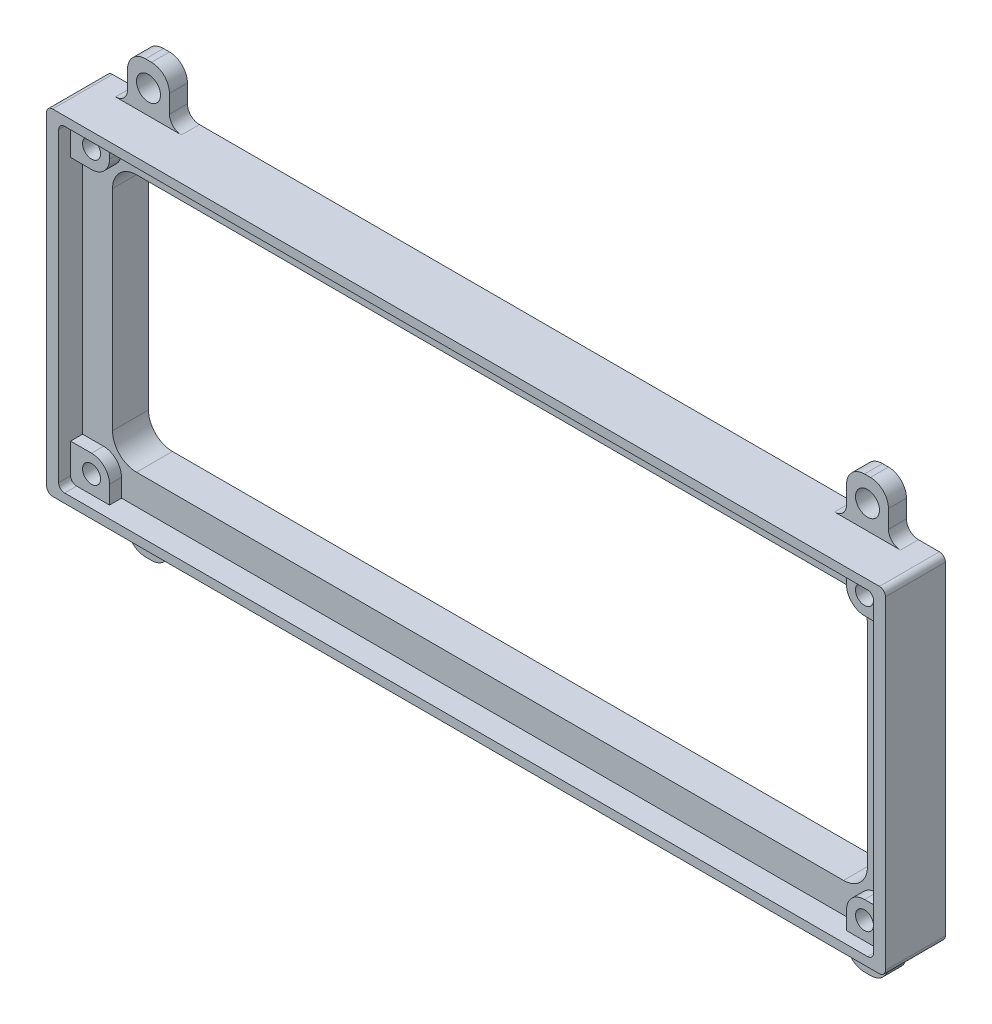
from build123d import *

# Parameters (mm, degrees)
SKETCH1_R               = 1.5
BOSS_EXTRUDE1_DEPTH     = 6
BOSS_EXTRUDE2_START     = 4
BOSS_EXTRUDE2_DEPTH     = 4
CUT_EXTRUDE1_DEPTH      = 151.903942957
CUT_EXTRUDE1_DEPTH_BACK = 151.903942957
SKETCH3_R               = 2
BOSS_EXTRUDE3_DEPTH     = 3
FILLET1_R               = 2
BOSS_EXTRUDE4_START     = 2
SKETCH4_R               = 1.5
BOSS_EXTRUDE4_DEPTH     = 2


with BuildPart() as part:
    # Sketch1 → Boss-Extrude1 (new body)
    with BuildSketch(Plane.XY):
        with BuildLine():
            ThreePointArc((0, 1), (0.292893219, 0.292893219), (1, 0))
            Line((1, 0), (139, 0))
            ThreePointArc((139, 0), (139.707106781, 0.292893219), (140, 1))
            Line((140, 1), (140, 55))
            ThreePointArc((140, 55), (139.707106781, 55.707106781), (139, 56))
            Line((139, 56), (1, 56))
            ThreePointArc((1, 56), (0.292893219, 55.707106781), (0, 55))
            Line((0, 55), (0, 1))
        make_face()
        with Locations((5.5, 4.5)):
            Circle(SKETCH1_R, mode=Mode.SUBTRACT)
        with Locations((134.5, 4.5)):
            Circle(SKETCH1_R, mode=Mode.SUBTRACT)
        with Locations((5.5, 51.5)):
            Circle(SKETCH1_R, mode=Mode.SUBTRACT)
        with Locations((134.5, 51.5)):
            Circle(SKETCH1_R, mode=Mode.SUBTRACT)
    extrude(amount=-BOSS_EXTRUDE1_DEPTH)

    # Sketch1_3 → Boss-Extrude2 (add)
    with BuildSketch(Plane.XY.offset(BOSS_EXTRUDE2_START)):
        with BuildLine():
            ThreePointArc((0, 1), (0.292893219, 0.292893219), (1, 0))
            Line((1, 0), (139, 0))
            ThreePointArc((139, 0), (139.707106781, 0.292893219), (140, 1))
            Line((140, 1), (140, 55))
            ThreePointArc((140, 55), (139.707106781, 55.707106781), (139, 56))
            Line((139, 56), (1, 56))
            ThreePointArc((1, 56), (0.292893219, 55.707106781), (0, 55))
            Line((0, 55), (0, 1))
        make_face()
        with BuildLine():
            ThreePointArc((2, 53.5), (2.292893219, 54.207106781), (3, 54.5))
            Line((3, 54.5), (137, 54.5))
            ThreePointArc((137, 54.5), (137.707106781, 54.207106781), (138, 53.5))
            Line((138, 53.5), (138, 2.5))
            ThreePointArc((138, 2.5), (137.707106781, 1.792893219), (137, 1.5))
            Line((137, 1.5), (3, 1.5))
            ThreePointArc((3, 1.5), (2.292893219, 1.792893219), (2, 2.5))
            Line((2, 2.5), (2, 53.5))
        make_face(mode=Mode.SUBTRACT)
    extrude(amount=-BOSS_EXTRUDE2_DEPTH)

    # Sketch2 → Cut-Extrude1 (cut, two sides: drawn at the far end of the back side and taken through both)
    with BuildSketch(Plane.XY.offset(-CUT_EXTRUDE1_DEPTH_BACK)):
        with BuildLine():
            Line((11, 49.5), (129, 49.5))
            ThreePointArc((129, 49.5), (131.828427125, 48.328427125), (133, 45.5))
            Line((133, 45.5), (133, 10.5))
            ThreePointArc((133, 10.5), (131.828427125, 7.671572875), (129, 6.5))
            Line((129, 6.5), (11, 6.5))
            ThreePointArc((11, 6.5), (8.171572875, 7.671572875), (7, 10.5))
            Line((7, 10.5), (7, 45.5))
            ThreePointArc((7, 45.5), (8.171572875, 48.328427125), (11, 49.5))
        make_face()
    extrude(amount=CUT_EXTRUDE1_DEPTH + CUT_EXTRUDE1_DEPTH_BACK, mode=Mode.SUBTRACT)

    # Sketch3 → Boss-Extrude3 (add)
    # profile 1 of 4: a face of its own
    with BuildSketch(Plane(origin=(0, 0, -6), x_dir=(-1, 0, 0), z_dir=(0, 0, -1))):
        with BuildLine():
            Line((-6.5, 0), (-6.5, -5))
            ThreePointArc((-6.5, -5), (-7.378679656, -7.121320344), (-9.5, -8))
            Line((-9.5, -8), (-10.5, -8))
            ThreePointArc((-10.5, -8), (-12.621320344, -7.121320344), (-13.5, -5))
            Line((-13.5, -5), (-13.5, 0))
            Line((-13.5, 0), (-6.5, 0))
        make_face()
        with Locations((-10, -4)):
            Circle(SKETCH3_R, mode=Mode.SUBTRACT)
    # profile 2 of 4: a face of its own
    with BuildSketch(Plane(origin=(0, 0, -6), x_dir=(-1, 0, 0), z_dir=(0, 0, -1))):
        with BuildLine():
            Line((-6.5, 56), (-13.5, 56))
            Line((-13.5, 56), (-13.5, 61))
            ThreePointArc((-13.5, 61), (-12.621320344, 63.121320344), (-10.5, 64))
            Line((-10.5, 64), (-9.5, 64))
            ThreePointArc((-9.5, 64), (-7.378679656, 63.121320344), (-6.5, 61))
            Line((-6.5, 61), (-6.5, 56))
        make_face()
        with Locations((-10, 60)):
            Circle(SKETCH3_R, mode=Mode.SUBTRACT)
    # profile 3 of 4: a face of its own
    with BuildSketch(Plane(origin=(0, 0, -6), x_dir=(-1, 0, 0), z_dir=(0, 0, -1))):
        with BuildLine():
            Line((-126.5, 56), (-126.5, 61))
            ThreePointArc((-126.5, 61), (-127.378679656, 63.121320344), (-129.5, 64))
            Line((-129.5, 64), (-130.5, 64))
            ThreePointArc((-130.5, 64), (-132.621320344, 63.121320344), (-133.5, 61))
            Line((-133.5, 61), (-133.5, 56))
            Line((-133.5, 56), (-126.5, 56))
        make_face()
        with Locations((-130, 60)):
            Circle(SKETCH3_R, mode=Mode.SUBTRACT)
    # profile 4 of 4: a face of its own
    with BuildSketch(Plane(origin=(0, 0, -6), x_dir=(-1, 0, 0), z_dir=(0, 0, -1))):
        with BuildLine():
            Line((-133.5, 0), (-133.5, -5))
            ThreePointArc((-133.5, -5), (-132.621320344, -7.121320344), (-130.5, -8))
            Line((-130.5, -8), (-129.5, -8))
            ThreePointArc((-129.5, -8), (-127.378679656, -7.121320344), (-126.5, -5))
            Line((-126.5, -5), (-126.5, 0))
            Line((-126.5, 0), (-133.5, 0))
        make_face()
        with Locations((-130, -4)):
            Circle(SKETCH3_R, mode=Mode.SUBTRACT)
    extrude(amount=-BOSS_EXTRUDE3_DEPTH)

    # Fillet1
    fillet1_edges = [part.edges().sort_by_distance(p)[0] for p in [
        (13.5, 56, -4.5),
        (6.5, 56, -4.5),
        (126.5, 56, -4.5),
        (133.5, 56, -4.5),
        (133.5, 0, -4.5),
        (126.5, 0, -4.5),
        (6.5, 0, -4.5),
        (13.5, 0, -4.5),
    ]]
    fillet(fillet1_edges, radius=FILLET1_R)

    # Sketch4 → Boss-Extrude4 (add)
    # profile 1 of 4: a face of its own
    with BuildSketch(Plane.XY.offset(BOSS_EXTRUDE4_START)):
        with BuildLine():
            Line((8.5, 51.5), (8.5, 54.880942349))
            Line((8.5, 54.880942349), (6, 54.880942349))
            Line((6, 54.880942349), (1.461490173, 54.880942349))
            Line((1.461490173, 54.880942349), (1.461490173, 48.5))
            Line((1.461490173, 48.5), (5.5, 48.5))
            ThreePointArc((5.5, 48.5), (7.621320344, 49.378679656), (8.5, 51.5))
        make_face()
        with Locations((5.5, 51.5)):
            Circle(SKETCH4_R, mode=Mode.SUBTRACT)
    # profile 2 of 4: a face of its own
    with BuildSketch(Plane.XY.offset(BOSS_EXTRUDE4_START)):
        with BuildLine():
            Line((134, 54.880942349), (131.5, 54.880942349))
            Line((131.5, 54.880942349), (131.5, 51.5))
            ThreePointArc((131.5, 51.5), (132.378679656, 49.378679656), (134.5, 48.5))
            Line((134.5, 48.5), (138.538509827, 48.5))
            Line((138.538509827, 48.5), (138.538509827, 54.880942349))
            Line((138.538509827, 54.880942349), (134, 54.880942349))
        make_face()
        with Locations((134.5, 51.5)):
            Circle(SKETCH4_R, mode=Mode.SUBTRACT)
    # profile 3 of 4: a face of its own
    with BuildSketch(Plane.XY.offset(BOSS_EXTRUDE4_START)):
        with BuildLine():
            Line((131.5, 4.5), (131.5, 1.119057651))
            Line((131.5, 1.119057651), (134, 1.119057651))
            Line((134, 1.119057651), (138.538509827, 1.119057651))
            Line((138.538509827, 1.119057651), (138.538509827, 7.5))
            Line((138.538509827, 7.5), (134.5, 7.5))
            ThreePointArc((134.5, 7.5), (132.378679656, 6.621320344), (131.5, 4.5))
        make_face()
        with Locations((134.5, 4.5)):
            Circle(SKETCH4_R, mode=Mode.SUBTRACT)
    # profile 4 of 4: a face of its own
    with BuildSketch(Plane.XY.offset(BOSS_EXTRUDE4_START)):
        with BuildLine():
            Line((6, 1.119057651), (8.5, 1.119057651))
            Line((8.5, 1.119057651), (8.5, 4.5))
            ThreePointArc((8.5, 4.5), (7.621320344, 6.621320344), (5.5, 7.5))
            Line((5.5, 7.5), (1.461490173, 7.5))
            Line((1.461490173, 7.5), (1.461490173, 1.119057651))
            Line((1.461490173, 1.119057651), (6, 1.119057651))
        make_face()
        with Locations((5.5, 4.5)):
            Circle(SKETCH4_R, mode=Mode.SUBTRACT)
    extrude(amount=-BOSS_EXTRUDE4_DEPTH)


solid = part.part
